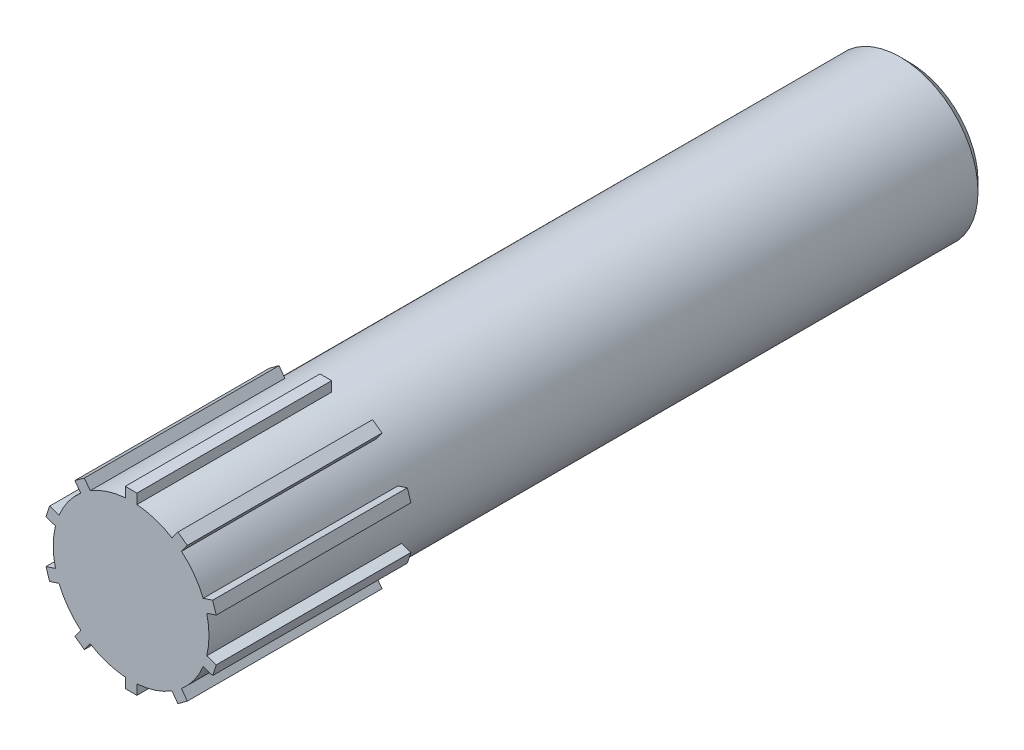
from build123d import *

# Parameters (mm, degrees)
SKETCH1_R           = 4
BOSS_EXTRUDE1_DEPTH = 40
CUT_EXTRUDE1_START  = -2.5
CUT_EXTRUDE1_DEPTH  = 2.5
SKETCH3_W           = 0.6
SKETCH3_H           = 1.963551659
BOSS_EXTRUDE2_DEPTH = 10
CIRPATTERN1_COUNT   = 10
CHAMFER1_SIZE       = 0.5


with BuildPart() as part:
    # Sketch1 → Boss-Extrude1 (new body)
    with BuildSketch(Plane.XY):
        Circle(SKETCH1_R)
    extrude(amount=BOSS_EXTRUDE1_DEPTH)

    # Sketch2 → Cut-Extrude1 (cut, through all)
    with BuildSketch(Plane(origin=(0, 0, 0), x_dir=(1, 0, 0), z_dir=(0, 1, 0)).offset(CUT_EXTRUDE1_START)):
        with BuildLine():
            Line((1.5, -5), (1.5, -9))
            ThreePointArc((1.5, -9), (0, -10.5), (-1.5, -9))
            Line((-1.5, -9), (-1.5, -5))
            ThreePointArc((-1.5, -5), (0, -3.5), (1.5, -5))
        make_face()
    extrude(amount=-CUT_EXTRUDE1_DEPTH, mode=Mode.SUBTRACT)

    # Sketch3 → Boss-Extrude2 (add)
    with BuildSketch(Plane.XY.offset(40)):
        with Locations((0, 3.51822417)):
            Rectangle(SKETCH3_W, SKETCH3_H)
    boss_extrude2 = extrude(amount=-BOSS_EXTRUDE2_DEPTH)

    # CirPattern1: Boss-Extrude2 ×10 about axis
    cirpattern1_axis = Axis((0, 0, 0), (0, 0, 1))
    for i in range(1, CIRPATTERN1_COUNT):
        add(boss_extrude2.rotate(cirpattern1_axis, i * 360 / CIRPATTERN1_COUNT))

    # Chamfer1
    chamfer1_edges = [part.edges().sort_by_distance(p)[0] for p in [
        (-4, 0, 0),
    ]]
    chamfer(chamfer1_edges, length=CHAMFER1_SIZE)


solid = part.part
